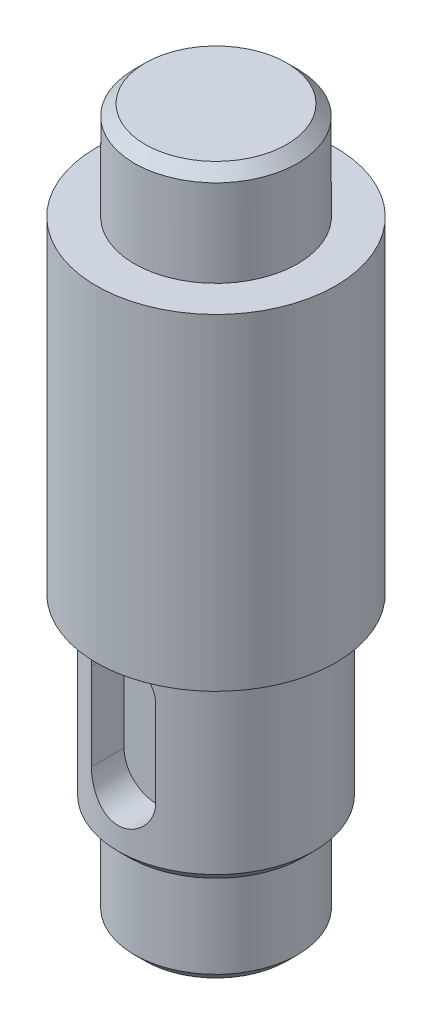
from build123d import *

# Parameters (mm, degrees)
CHAMFER1_SIZE      = 1
CUT_EXTRUDE1_DEPTH = 3.5


with BuildPart() as part:
    # Sketch1 → Revolve1 (revolve)
    with BuildSketch(Plane.XY):
        Polygon((0, 0), (7.5, 0), (7.5, -9), (11, -9), (11, -39), (9, -39), (9, -56), (7.5, -56), (7.5, -65), (0, -65), align=None)
    revolve(axis=Axis((0, -65, 0), (0, 1, 0)))

    # Chamfer1
    chamfer1_edges = [part.edges().sort_by_distance(p)[0] for p in [
        (-7.5, 0, 0),
        (-7.5, -65, 0),
        (-9, -56, 0),
    ]]
    chamfer(chamfer1_edges, length=CHAMFER1_SIZE)

    # Sketch4 → Cut-Extrude1 (cut)
    with BuildSketch(Plane.XY.offset(9)):
        with BuildLine():
            Line((2.952489762, -42), (2.952489762, -50))
            ThreePointArc((2.952489762, -50), (0, -52.952489762), (-2.952489762, -50))
            Line((-2.952489762, -50), (-2.952489762, -42))
            ThreePointArc((-2.952489762, -42), (0, -39.047510238), (2.952489762, -42))
        make_face()
    extrude(amount=-CUT_EXTRUDE1_DEPTH, mode=Mode.SUBTRACT)


solid = part.part
